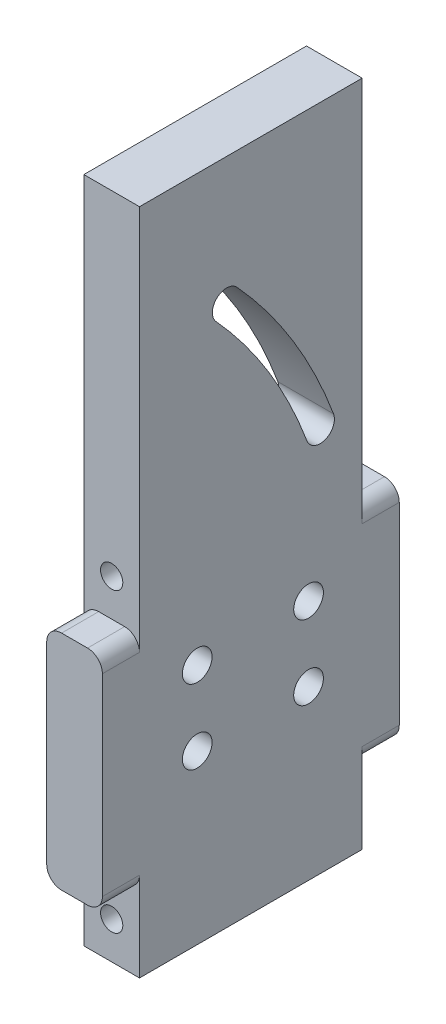
from build123d import *

# Parameters (mm, degrees)
BOSS_EXTRUDE1_DEPTH = 19.05
SKETCH2_R           = 3.81
CUT_EXTRUDE1_DEPTH  = 89.9
SKETCH3_R           = 3.81
CUT_EXTRUDE2_DEPTH  = 89.9
SKETCH4_R           = 5.08
CUT_EXTRUDE3_DEPTH  = 20.05
FILLET1_R           = 5.08


with BuildPart() as part:
    # Sketch1 → Boss-Extrude1 (new body)
    with BuildSketch(Plane(origin=(0, 0, 0), x_dir=(0, 0, -1), z_dir=(1, 0, 0))):
        Polygon((0, 0), (0, 25.4), (-12.7, 25.4), (-12.7, 101.6), (0, 101.6), (0, 228.6), (76.2, 228.6), (76.2, 101.6), (88.9, 101.6), (88.9, 25.4), (76.2, 25.4), (76.2, 0), align=None)
    extrude(amount=BOSS_EXTRUDE1_DEPTH)

    # Sketch2 → Cut-Extrude1 (cut, through all)
    with BuildSketch(Plane.XY):
        with Locations((9.525, 114.3)):
            Circle(SKETCH2_R)
    extrude(amount=-CUT_EXTRUDE1_DEPTH, mode=Mode.SUBTRACT)

    # Sketch3 → Cut-Extrude2 (cut, through all)
    with BuildSketch(Plane.XY):
        with Locations((9.525, 12.7)):
            Circle(SKETCH3_R)
    extrude(amount=-CUT_EXTRUDE2_DEPTH, mode=Mode.SUBTRACT)

    # Sketch4 → Cut-Extrude3 (cut, through all)
    with BuildSketch(Plane(origin=(19.05, 0, 0), x_dir=(0, 0, -1), z_dir=(1, 0, 0))):
        with Locations((19.755070015, 57.415301139)):
            Circle(SKETCH4_R)
        with Locations((57.855070015, 57.415301139)):
            Circle(SKETCH4_R)
        with Locations((19.755070015, 82.815301139)):
            Circle(SKETCH4_R)
        with Locations((57.855070015, 82.815301139)):
            Circle(SKETCH4_R)
        with BuildLine():
            ThreePointArc((66.388980032, 134.027277083), (52.493130024, 162.609745262), (33.396209532, 188.013677287))
            ThreePointArc((33.396209532, 188.013677287), (26.516800005, 188.321710549), (26.208766742, 181.442301021))
            ThreePointArc((26.208766742, 181.442301021), (44.183346452, 157.531377723), (57.262526611, 130.628723299))
            ThreePointArc((57.262526611, 130.628723299), (63.525030214, 127.76477348), (66.388980032, 134.027277083))
        make_face()
    extrude(amount=-CUT_EXTRUDE3_DEPTH, mode=Mode.SUBTRACT)

    # Fillet1
    fillet1_edges = [part.edges().sort_by_distance(p)[0] for p in [
        (19.05, 25.4, -82.55),
        (0, 25.4, 6.35),
        (0, 101.6, 6.35),
        (0, 101.6, -82.55),
        (0, 25.4, -82.55),
        (19.05, 101.6, -82.55),
        (19.05, 101.6, 6.35),
        (19.05, 25.4, 6.35),
    ]]
    fillet(fillet1_edges, radius=FILLET1_R)


solid = part.part
